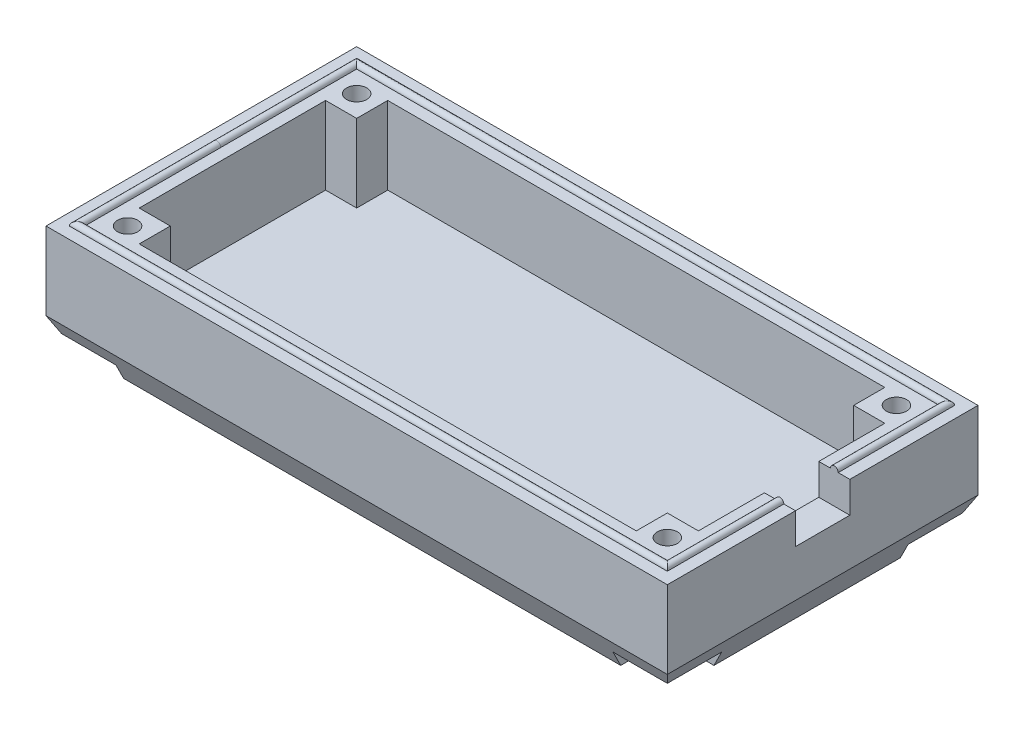
from build123d import *

# Parameters (mm, degrees)
SCHIZZO2_W                     = 40
SCHIZZO2_H                     = 20
ESTRUSIONE_ESTRUSIONE1_DEPTH   = 7
TAGLIO_ESTRUSIONE1_DEPTH       = 5
SMUSSO1_SIZE                   = 1
SMUSSO1_SIZE2                  = 2
SCHIZZO6_W                     = 4
SCHIZZO6_H                     = 4
TAGLIO_ESTRUSIONE2_DEPTH       = 1
FORO_PER_VITE_M1_1_D           = 1.3
FORO_PER_VITE_M1_1_CSINK_D     = 1.35
FORO_PER_VITE_M1_1_CSINK_ANGLE = 90
SPECCHIA2_COPY_1_D             = 1.3
SPECCHIA2_COPY_1_CSINK_D       = 1.35
SPECCHIA2_COPY_1_CSINK_ANGLE   = 90
SCHIZZO14_W                    = 3.5
SCHIZZO14_H                    = 4
TAGLIO_ESTRUSIONE3_DEPTH       = 1
TAGLIO_ESTRUSIONE3_DEPTH_BACK  = 3


with BuildPart() as part:
    # Schizzo2 → Estrusione-Estrusione1 (new body)
    with BuildSketch(Plane(origin=(0, 0, 0), x_dir=(1, 0, 0), z_dir=(0, 1, 0))):
        Rectangle(SCHIZZO2_W, SCHIZZO2_H)
    extrude(amount=-ESTRUSIONE_ESTRUSIONE1_DEPTH)

    # Schizzo3 → Taglio-Estrusione1 (cut)
    with BuildSketch(Plane(origin=(0, 0, 0), x_dir=(1, 0, 0), z_dir=(0, 1, 0))):
        Polygon((-16, 8), (16, 8), (16, 6), (18, 6), (18, -6), (16, -6), (16, -8), (-16, -8), (-16, -6), (-18, -6), (-18, 6), (-16, 6), align=None)
    extrude(amount=-TAGLIO_ESTRUSIONE1_DEPTH, mode=Mode.SUBTRACT)

    # Sweep1: sweep along a path in Schizzo5
    with BuildLine(Plane(origin=(0, 0, 0), x_dir=(1, 0, 0), z_dir=(0, 1, 0))) as sweep1_path:
        Line((19, -9), (-19, -9))
        Line((-19, -9), (-19, 9))
        Line((-19, 9), (19, 9))
        Line((19, 9), (19, -9))
    # Schizzo4 → Sweep1 (sweep)
    with BuildSketch(Plane.XY):
        with BuildLine():
            Line((-18.75, 0), (-19.25, 0))
            ThreePointArc((-19.25, 0), (-19, 0.25), (-18.75, 0))
        make_face()
    sweep(path=sweep1_path.line, transition=Transition.RIGHT)

    # Smusso1
    smusso1_edges = [part.edges().sort_by_distance(p)[0] for p in [
        (20, -7, 0),
        (0, -7, -10),
        (-20, -7, 0),
        (0, -7, 10),
    ]]
    smusso1_side = [part.faces().sort_by_distance(p)[0] for p in [
        (0, -7, 0),
    ]]
    chamfer(smusso1_edges, length=SMUSSO1_SIZE, length2=SMUSSO1_SIZE2, reference=smusso1_side[0])

    # Schizzo6 → Taglio-Estrusione2 (cut)
    with BuildSketch(Plane.XZ.offset(7)):
        with Locations((-18, 8)):
            Rectangle(SCHIZZO6_W, SCHIZZO6_H)
        with Locations((18, 8)):
            Rectangle(SCHIZZO6_W, SCHIZZO6_H)
        with Locations((18, -8)):
            Rectangle(SCHIZZO6_W, SCHIZZO6_H)
        with Locations((-18, -8)):
            Rectangle(SCHIZZO6_W, SCHIZZO6_H)
    extrude(amount=-TAGLIO_ESTRUSIONE2_DEPTH, mode=Mode.SUBTRACT)

    # Foro per Vite M1-1 (through all)
    with Locations(Plane(origin=(0, -6, 0), x_dir=(-1, 0, 0), z_dir=(0, -1, 0))):
        with Locations((-17.375, 7.375)):
            foro_per_vite_m1_1 = CounterSinkHole(FORO_PER_VITE_M1_1_D / 2, FORO_PER_VITE_M1_1_CSINK_D / 2, counter_sink_angle=FORO_PER_VITE_M1_1_CSINK_ANGLE)

    # Specchia1: Foro per Vite M1-1 across plane
    add(foro_per_vite_m1_1.mirror(Plane(origin=(0, 0, 0), x_dir=(0, 0, 1), z_dir=(1, 0, 0))), mode=Mode.SUBTRACT)

    # Specchia2: Foro per Vite M1-1 across plane
    add(foro_per_vite_m1_1.mirror(Plane.XY), mode=Mode.SUBTRACT)

    # Specchia2 copy 1 (through all)
    with Locations(Plane.XZ.offset(6)):
        with Locations((-17.375, 7.375)):
            CounterSinkHole(SPECCHIA2_COPY_1_D / 2, SPECCHIA2_COPY_1_CSINK_D / 2, counter_sink_angle=SPECCHIA2_COPY_1_CSINK_ANGLE)

    # Schizzo14 → Taglio-Estrusione3 (cut, two sides)
    with BuildSketch(Plane(origin=(20, 0, 0), x_dir=(0, 0, -1), z_dir=(1, 0, 0))) as taglio_estrusione3_sk:
        Rectangle(SCHIZZO14_W, SCHIZZO14_H)
    extrude(amount=TAGLIO_ESTRUSIONE3_DEPTH, mode=Mode.SUBTRACT)
    extrude(taglio_estrusione3_sk.sketch, amount=-TAGLIO_ESTRUSIONE3_DEPTH_BACK, mode=Mode.SUBTRACT)


solid = part.part
